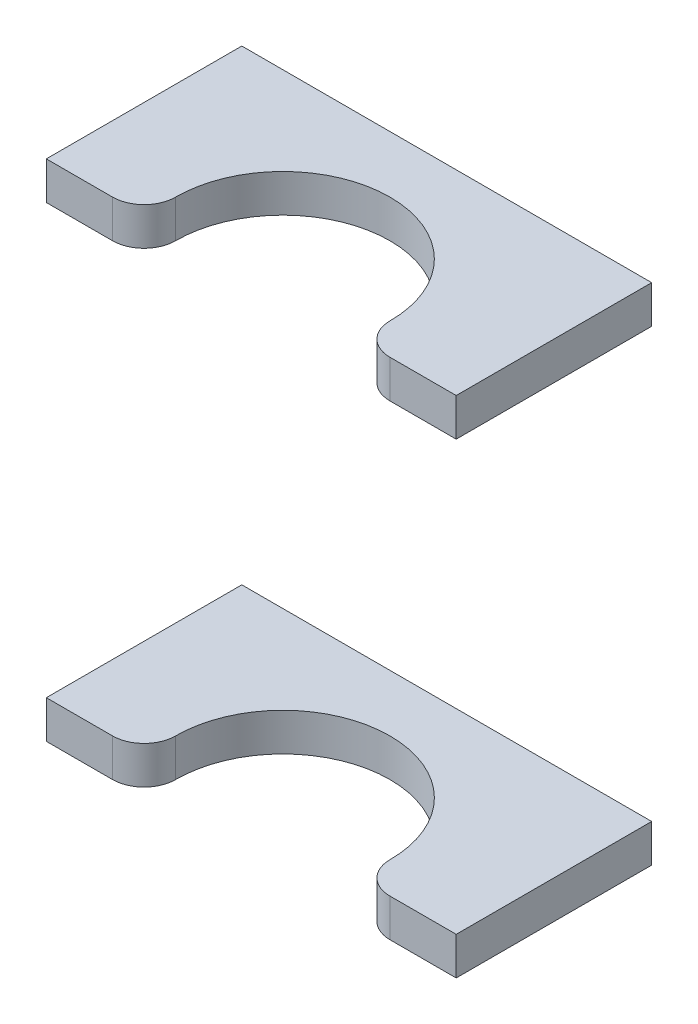
from build123d import *

# Parameters (mm, degrees)
SKETCH1_W             = 65
SKETCH1_H             = 6
BOSS_EXTRUDE1_DEPTH   = 46
BOSS_EXTRUDE1_2_DEPTH = 46
CUT_EXTRUDE4_DEPTH    = 81


with BuildPart() as part:
    # Sketch1 → Boss-Extrude1 (new body)
    with BuildSketch(Plane.XY):
        with Locations((-347.5, 23)):
            Rectangle(SKETCH1_W, SKETCH1_H)
    extrude(amount=BOSS_EXTRUDE1_DEPTH)


with BuildPart() as body_2:
    # Sketch1 → Boss-Extrude1 2 (new body)
    with BuildSketch(Plane.XY):
        with Locations((-347.5, 97)):
            Rectangle(SKETCH1_W, SKETCH1_H)
    extrude(amount=BOSS_EXTRUDE1_2_DEPTH)


with BuildPart() as cut_extrude4_tool:
    # Sketch4 → Cut-Extrude4 (new body, through all)
    with BuildSketch(Plane(origin=(0, 20, 0), x_dir=(-1, 0, 0), z_dir=(0, -1, 0))):
        with BuildLine():
            Line((315, -31), (315, -46))
            Line((315, -46), (380, -46))
            Line((380, -46), (380, -31))
            Line((380, -31), (369.5, -31))
            ThreePointArc((369.5, -31), (365.964466094, -29.535533906), (364.5, -26))
            ThreePointArc((364.5, -26), (347.5, -9), (330.5, -26))
            ThreePointArc((330.5, -26), (329.035533906, -29.535533906), (325.5, -31))
            Line((325.5, -31), (315, -31))
        make_face()
    extrude(amount=-CUT_EXTRUDE4_DEPTH)


with BuildPart() as part_1:
    add(part.part)

    # Cut-Extrude4: cut by cut_extrude4_tool
    add(cut_extrude4_tool.part, mode=Mode.SUBTRACT)


with BuildPart() as body_2_1:
    add(body_2.part)

    # Cut-Extrude4: cut by cut_extrude4_tool
    add(cut_extrude4_tool.part, mode=Mode.SUBTRACT)


solid = Compound([part_1.part, body_2_1.part])
